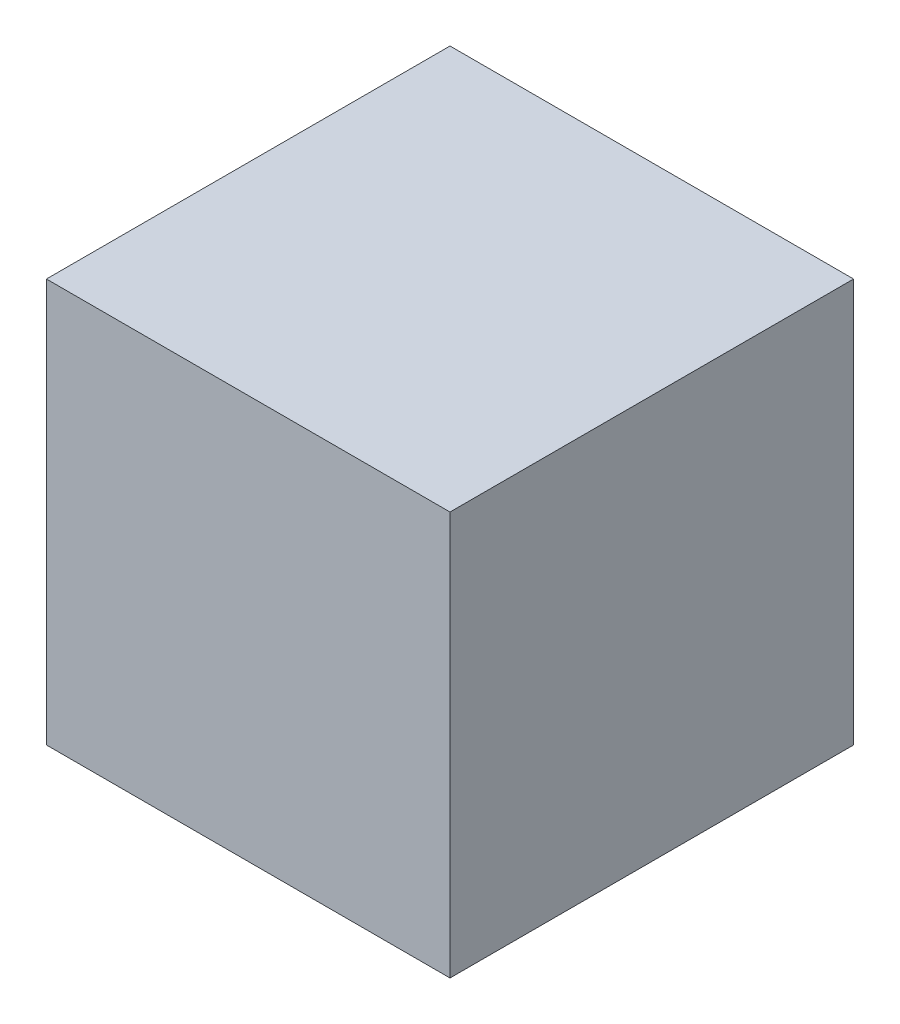
from build123d import *

# Parameters (mm, degrees)
SKETCH_1_W      = 200
SKETCH_1_H      = 200
EXTRUDE_1_DEPTH = 200


with BuildPart() as part:
    # Эскиз1 → Бобышка-Вытянуть1 (new body)
    with BuildSketch(Plane.XY):
        Rectangle(SKETCH_1_W, SKETCH_1_H)
    extrude(amount=EXTRUDE_1_DEPTH)


solid = part.part
